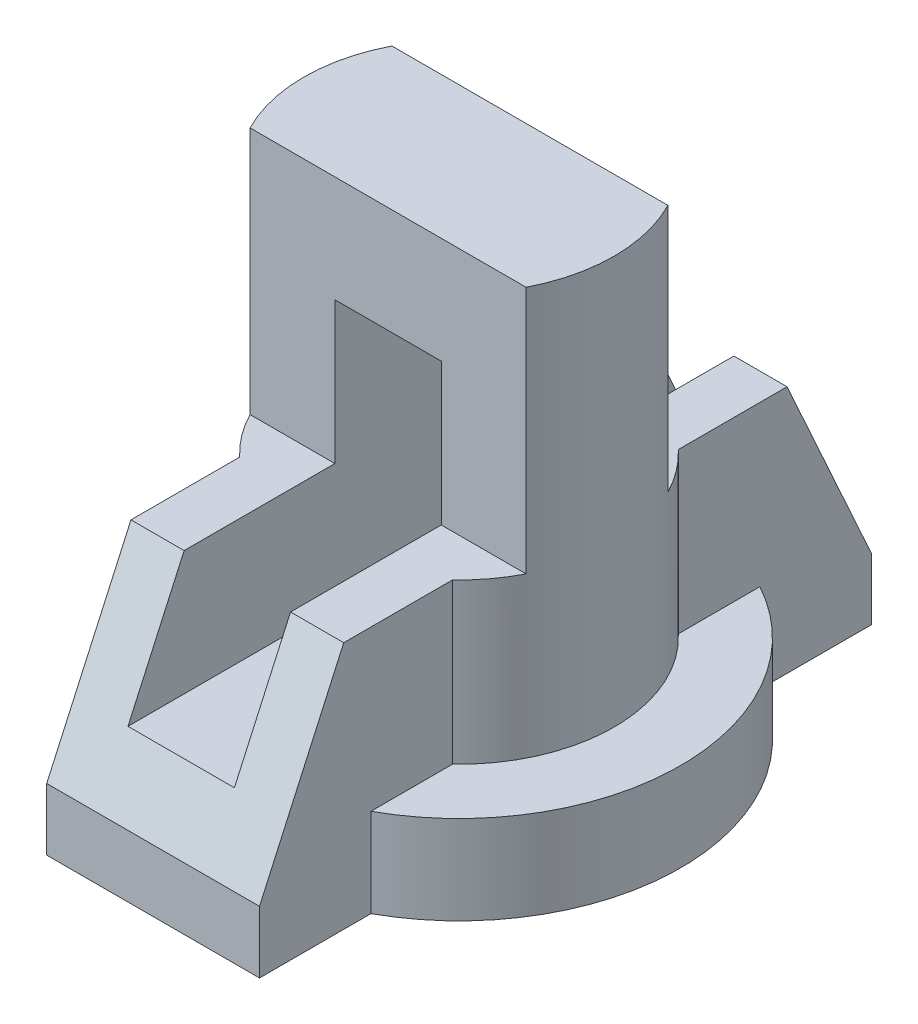
from build123d import *

# Parameters (mm, degrees)
SKETCH1_R               = 25
BOSS_EXTRUDE1_DEPTH     = 10
SKETCH2_R               = 17.5
BOSS_EXTRUDE2_DEPTH     = 18
BOSS_EXTRUDE3_DEPTH     = 28
BOSS_EXTRUDE6_DEPTH     = 12
SKETCH5_W               = 12
SKETCH5_H               = 30
CUT_EXTRUDE3_DEPTH      = 35.5
CUT_EXTRUDE3_DEPTH_BACK = 35.5


with BuildPart() as part:
    # Sketch1 → Boss-Extrude1 (new body)
    with BuildSketch(Plane(origin=(0, 0, 0), x_dir=(1, 0, 0), z_dir=(0, 1, 0))):
        Circle(SKETCH1_R)
    extrude(amount=BOSS_EXTRUDE1_DEPTH)

    # Sketch2 → Boss-Extrude2 (add)
    with BuildSketch(Plane(origin=(0, 10, 0), x_dir=(1, 0, 0), z_dir=(0, 1, 0))):
        Circle(SKETCH2_R)
    extrude(amount=BOSS_EXTRUDE2_DEPTH)

    # Sketch3 → Boss-Extrude3 (add)
    with BuildSketch(Plane(origin=(0, 28, 0), x_dir=(1, 0, 0), z_dir=(0, 1, 0))):
        with BuildLine():
            Line((-15.564382416, -8), (15.564382416, -8))
            ThreePointArc((15.564382416, -8), (17.5, 0), (15.564382416, 8))
            Line((15.564382416, 8), (-15.564382416, 8))
            ThreePointArc((-15.564382416, 8), (-17.5, 0), (-15.564382416, -8))
        make_face()
    extrude(amount=BOSS_EXTRUDE3_DEPTH)

    # Sketch4 → Boss-Extrude6 (add, symmetric)
    with BuildSketch(Plane(origin=(0, 0, 0), x_dir=(0, 0, -1), z_dir=(1, 0, 0))):
        Polygon((34.5, 0), (34.5, 7), (25, 28), (-25, 28), (-34.5, 7), (-34.5, 0), align=None)
    extrude(amount=BOSS_EXTRUDE6_DEPTH, both=True)

    # Sketch5 → Cut-Extrude3 (cut, two sides)
    with BuildSketch(Plane.XY) as cut_extrude3_sk:
        with Locations((0, 29)):
            Rectangle(SKETCH5_W, SKETCH5_H)
    extrude(amount=CUT_EXTRUDE3_DEPTH, mode=Mode.SUBTRACT)
    extrude(cut_extrude3_sk.sketch, amount=-CUT_EXTRUDE3_DEPTH_BACK, mode=Mode.SUBTRACT)


solid = part.part
